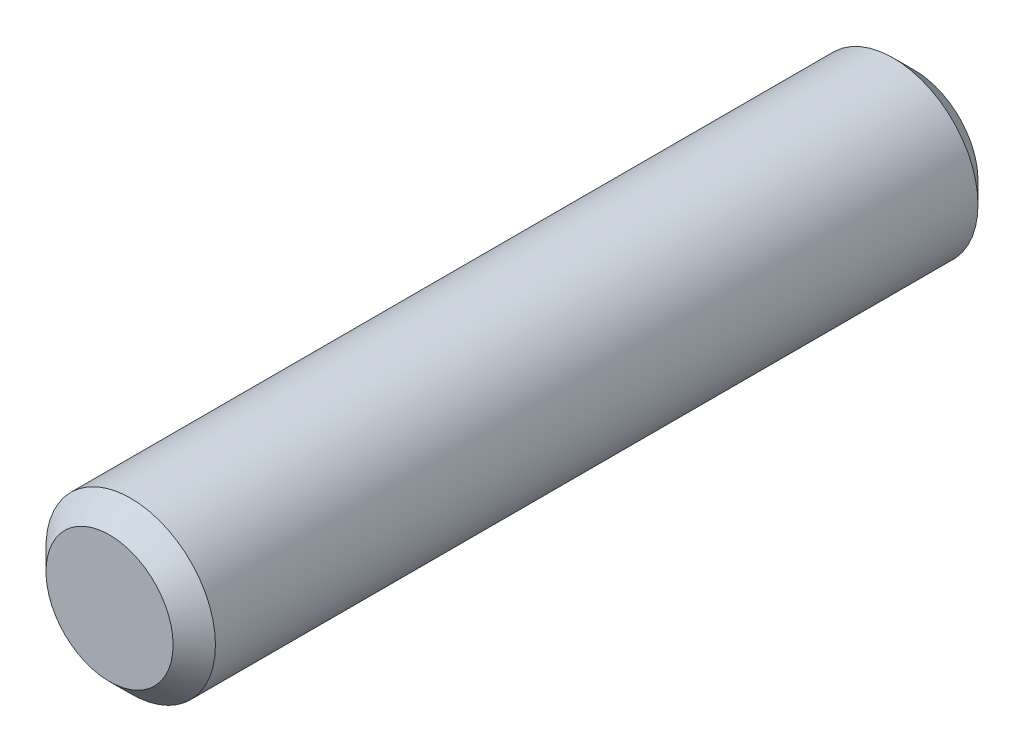
from build123d import *

# Parameters (mm, degrees)
SKETCH1_R           = 4
BOSS_EXTRUDE1_DEPTH = 38
CHAMFER1_SIZE       = 1


with BuildPart() as part:
    # Sketch1 → Boss-Extrude1 (new body)
    with BuildSketch(Plane.XY):
        Circle(SKETCH1_R)
    extrude(amount=BOSS_EXTRUDE1_DEPTH)

    # Chamfer1
    chamfer1_edges = [part.edges().sort_by_distance(p)[0] for p in [
        (-4, 0, 0),
        (-4, 0, 38),
    ]]
    chamfer(chamfer1_edges, length=CHAMFER1_SIZE)


solid = part.part
